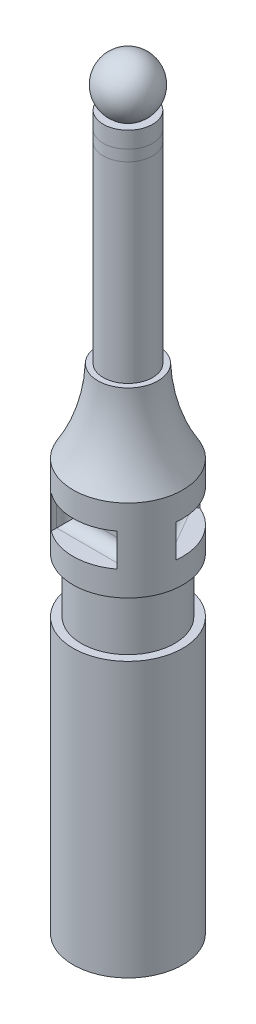
from build123d import *

# Parameters (mm, degrees)
SKETCH_3_W                       = 12
SKETCH_3_H                       = 6
CUT_EXTRUDE_1_DEPTH              = 19
FILLET_1_R                       = 2
PATTERN_CIRCULAR_1_COUNT         = 3
FILLET_1_OF_PATTERN_CIRCULAR_1_R = 2
SKETCH_6_R                       = 4.5
SKETCH_6_R_2                     = 0.0005
CUT_EXTRUDE_5_DEPTH              = 2
SKETCH_7_R                       = 4.5
EXTRUDE_3_DEPTH                  = 2


with BuildPart() as part:
    # 草图1 → 旋转1 (revolve)
    with BuildSketch(Plane.XY):
        with BuildLine():
            Line((-4.5, 96.457967635), (-3, 96.457967635))
            ThreePointArc((-3, 96.457967635), (-4.74341649, 102.039106465), (0, 105.457967635))
            Line((0, 105.457967635), (0, -33.542032365))
            Line((0, -33.542032365), (-10, -33.542032365))
            Line((-10, -33.542032365), (-10, 16.457967635))
            Line((-10, 16.457967635), (-8.5, 16.457967635))
            Line((-8.5, 16.457967635), (-8.5, 26.457967635))
            Line((-8.5, 26.457967635), (-10, 26.457967635))
            Line((-10, 26.457967635), (-10, 41.457967635))
            ThreePointArc((-10, 41.457967635), (-6.780641664, 48.667160134), (-5.5, 56.457967635))
            Line((-5.5, 56.457967635), (-4.5, 56.457967635))
            Line((-4.5, 56.457967635), (-4.5, 96.457967635))
        make_face()
    revolve(axis=Axis((0, 64.032798659, 0), (0, -1, 0)))

    # 草图3 → 切除-拉伸1 (cut)
    with BuildSketch(Plane.XY.offset(24)):
        with Locations((0, 33.957967635)):
            Rectangle(SKETCH_3_W, SKETCH_3_H)
    cut_extrude_1 = extrude(amount=-CUT_EXTRUDE_1_DEPTH, mode=Mode.SUBTRACT)

    # 圆角1
    fillet_1_edges = [part.edges().sort_by_distance(p)[0] for p in [
        (6, 33.957967635, 5),
        (0, 30.957967635, 5),
        (-6, 33.957967635, 5),
        (0, 36.957967635, 5),
    ]]
    fillet(fillet_1_edges, radius=FILLET_1_R)

    # 阵列(圆周)1: 切除-拉伸1 ×3 about axis
    pattern_circular_1_axis = Axis((0, 0, 0), (0, 1, 0))
    for i in range(1, PATTERN_CIRCULAR_1_COUNT):
        add(cut_extrude_1.rotate(pattern_circular_1_axis, i * 360 / PATTERN_CIRCULAR_1_COUNT), mode=Mode.SUBTRACT)

    # 圆角1 of 阵列(圆周)1
    fillet_1_of_pattern_circular_1_edges = [part.edges().sort_by_distance(p)[0] for p in [
        (1.330127019, 33.957967635, -7.696152423),
        (4.330127019, 30.957967635, -2.5),
        (7.330127019, 33.957967635, 2.696152423),
        (4.330127019, 36.957967635, -2.5),
        (-7.330127019, 33.957967635, 2.696152423),
        (-4.330127019, 30.957967635, -2.5),
        (-1.330127019, 33.957967635, -7.696152423),
        (-4.330127019, 36.957967635, -2.5),
    ]]
    fillet(fillet_1_of_pattern_circular_1_edges, radius=FILLET_1_OF_PATTERN_CIRCULAR_1_R)

    # 草图6 → 切除-拉伸5 (cut)
    with BuildSketch(Plane(origin=(0, 93.457967635, 0), x_dir=(1, 0, 0), z_dir=(0, 1, 0))):
        Circle(SKETCH_6_R)
        Circle(SKETCH_6_R_2, mode=Mode.SUBTRACT)
    extrude(amount=-CUT_EXTRUDE_5_DEPTH, mode=Mode.SUBTRACT)


with BuildPart() as body_2:
    # 草图7 → 凸台-拉伸3 (new body)
    with BuildSketch(Plane(origin=(0, 93.457967635, 0), x_dir=(1, 0, 0), z_dir=(0, 1, 0))):
        Circle(SKETCH_7_R)
    extrude(amount=-EXTRUDE_3_DEPTH)


solid = Compound([part.part, body_2.part])
